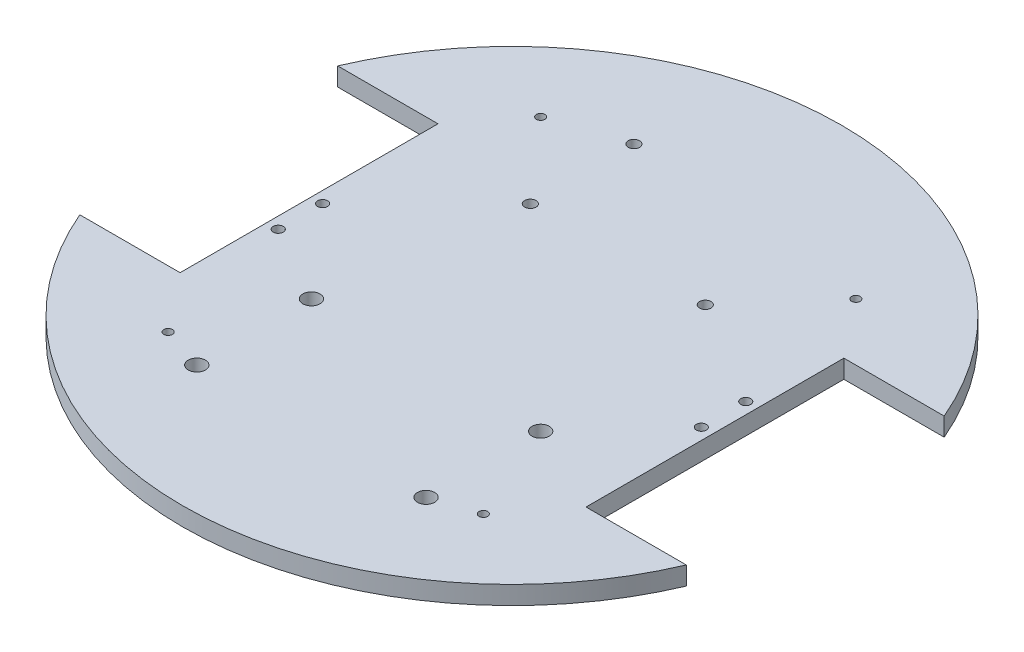
from build123d import *

# Parameters (mm, degrees)
SKETCH1_R             = 115
BOSS_EXTRUDE1_DEPTH   = 6.4
CUT_EXTRUDE1_DEPTH    = 7.5
SKETCH3_R             = 1.75
CUT_EXTRUDE2_DEPTH    = 7.4
SKETCH4_R             = 2
CUT_EXTRUDE3_DEPTH    = 7.4
SKETCH5_R             = 3
CUT_EXTRUDE4_DEPTH    = 7.4
F_3_0MM_DOWEL_HOLE1_D = 3


with BuildPart() as part:
    # Sketch1 → Boss-Extrude1 (new body)
    with BuildSketch(Plane(origin=(0, 0, 0), x_dir=(1, 0, 0), z_dir=(0, 1, 0))):
        Circle(SKETCH1_R)
    extrude(amount=BOSS_EXTRUDE1_DEPTH)

    # Sketch2 → Cut-Extrude1 (cut)
    with BuildSketch(Plane(origin=(0, 6.4, 0), x_dir=(1, 0, 0), z_dir=(0, 1, 0))):
        with BuildLine():
            Line((-105.830052443, 45), (-70.830052443, 45))
            Line((-70.830052443, 45), (-70.830052443, -45))
            Line((-70.830052443, -45), (-105.830052443, -45))
            ThreePointArc((-105.830052443, -45), (-115, 0), (-105.830052443, 45))
        make_face()
        with BuildLine():
            Line((105.830052443, -45), (70.830052443, -45))
            Line((70.830052443, -45), (70.830052443, 45))
            Line((70.830052443, 45), (105.830052443, 45))
            ThreePointArc((105.830052443, 45), (115, 0), (105.830052443, -45))
        make_face()
    extrude(amount=-CUT_EXTRUDE1_DEPTH, mode=Mode.SUBTRACT)

    # Sketch3 → Cut-Extrude2 (cut, through all)
    with BuildSketch(Plane(origin=(0, 6.4, 0), x_dir=(1, 0, 0), z_dir=(0, 1, 0))):
        with Locations((-66.830052443, 0.75)):
            Circle(SKETCH3_R)
        with Locations((-66.830052443, -14.75)):
            Circle(SKETCH3_R)
        with Locations((66.830052443, -0.75)):
            Circle(SKETCH3_R)
        with Locations((66.830052443, 14.75)):
            Circle(SKETCH3_R)
    extrude(amount=-CUT_EXTRUDE2_DEPTH, mode=Mode.SUBTRACT)

    # Sketch4 → Cut-Extrude3 (cut, through all)
    with BuildSketch(Plane(origin=(0, 6.4, 0), x_dir=(1, 0, 0), z_dir=(0, 1, 0))):
        with Locations((30.525, 36.93)):
            Circle(SKETCH4_R)
        with Locations((-30.525, 36.93)):
            Circle(SKETCH4_R)
        with Locations((-30.525, 73.07)):
            Circle(SKETCH4_R)
    extrude(amount=-CUT_EXTRUDE3_DEPTH, mode=Mode.SUBTRACT)

    # Sketch5 → Cut-Extrude4 (cut, through all)
    with BuildSketch(Plane(origin=(0, 6.4, 0), x_dir=(1, 0, 0), z_dir=(0, 1, 0))):
        with Locations((-40, -30)):
            Circle(SKETCH5_R)
        with Locations((40, -30)):
            Circle(SKETCH5_R)
        with Locations((40, -70)):
            Circle(SKETCH5_R)
        with Locations((-40, -70)):
            Circle(SKETCH5_R)
    extrude(amount=-CUT_EXTRUDE4_DEPTH, mode=Mode.SUBTRACT)

    # Ø3.0mm Dowel Hole1 (through all)
    with Locations(Plane(origin=(0, 0, 0), x_dir=(-1, 0, 0), z_dir=(0, -1, 0))):
        with Locations((-55, 65), (55, 65), (55, -65), (-55, -65)):
            Hole(F_3_0MM_DOWEL_HOLE1_D / 2)


solid = part.part
